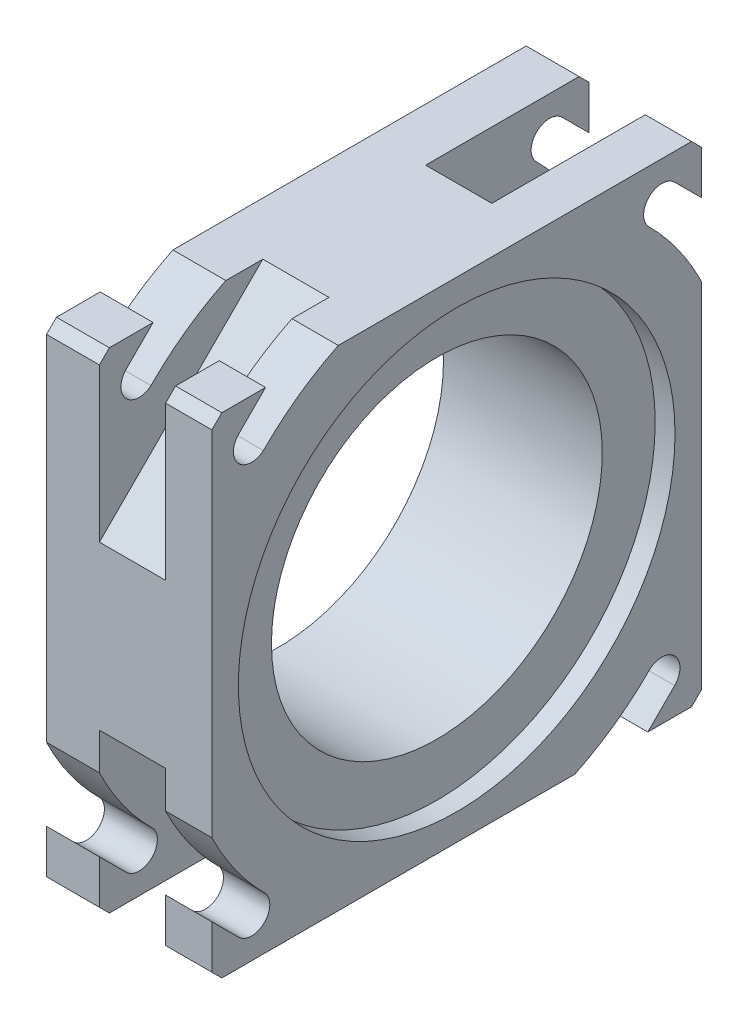
from build123d import *

# Parameters (mm, degrees)
ESBO_O1_W                                           = 74
ESBO_O1_H                                           = 74
RESSALTO_EXTRUS_O1_DEPTH                            = 25
CHANFRO1_SIZE                                       = 1.5
REBAIXO_PARA_PARAFUSO_COM_CABE_A_PANELA_D           = 50
REBAIXO_PARA_PARAFUSO_COM_CABE_A_PANELA_DEPTH       = 35
REBAIXO_PARA_PARAFUSO_COM_CABE_A_PANELA_CBORE_D     = 66
REBAIXO_PARA_PARAFUSO_COM_CABE_A_PANELA_CBORE_DEPTH = 3
REBAIXO_PARA_PARAFUSO_COM_CABE_A_PANELA_TIP         = 15.021515476
ESBO_O4_W                                           = 10
ESBO_O4_H                                           = 50
CORTE_EXTRUS_O1_DEPTH                               = 16.4
ESBO_O6_W                                           = 10
ESBO_O6_H                                           = 50
CORTE_EXTRUS_O2_DEPTH                               = 16.4
CORTE_EXTRUS_O4_REACH                               = 19.461
ESBO_O11_W                                          = 10
ESBO_O11_H                                          = 50
CORTE_EXTRUS_O3_DEPTH                               = 7
PADR_OCIRCULAR1_COUNT                               = 4
ESBO_O13_R                                          = 33
ESBO_O13_R_2                                        = 25
RESSALTO_EXTRUS_O2_DEPTH                            = 2
ESBO_O14_R                                          = 35.5
ESBO_O14_R_2                                        = 33
CORTE_EXTRUS_O5_DEPTH                               = 3.5
CORTE_EXTRUS_O10_DEPTH                              = 8
PADR_OCIRCULAR2_COUNT                               = 4
FILETE1_R                                           = 0.25
FILETE2_R                                           = 0.15


with BuildPart() as part:
    # Esboço1 → Ressalto-extrusão1 (new body)
    with BuildSketch(Plane(origin=(0, 0, 0), x_dir=(0, 0, -1), z_dir=(1, 0, 0))):
        with Locations((37, 37)):
            Rectangle(ESBO_O1_W, ESBO_O1_H)
    extrude(amount=RESSALTO_EXTRUS_O1_DEPTH)

    # Chanfro1
    chanfro1_edges = [part.edges().sort_by_distance(p)[0] for p in [
        (12.5, 74, 0),
        (12.5, 74, -74),
        (12.5, 0, -74),
        (12.5, 0, 0),
    ]]
    chamfer(chanfro1_edges, length=CHANFRO1_SIZE)

    # Rebaixo para parafuso com cabeça panela de M21
    with Locations(Plane(origin=(25, 0, 0), x_dir=(0, 0, -1), z_dir=(1, 0, 0))):
        with Locations((37, 37)):
            CounterBoreHole(REBAIXO_PARA_PARAFUSO_COM_CABE_A_PANELA_D / 2, REBAIXO_PARA_PARAFUSO_COM_CABE_A_PANELA_CBORE_D / 2, REBAIXO_PARA_PARAFUSO_COM_CABE_A_PANELA_CBORE_DEPTH, depth=REBAIXO_PARA_PARAFUSO_COM_CABE_A_PANELA_DEPTH)
            with Locations((0, 0, -(REBAIXO_PARA_PARAFUSO_COM_CABE_A_PANELA_DEPTH + REBAIXO_PARA_PARAFUSO_COM_CABE_A_PANELA_TIP / 2))):  # 118° drill point
                Cone(0, REBAIXO_PARA_PARAFUSO_COM_CABE_A_PANELA_D / 2, REBAIXO_PARA_PARAFUSO_COM_CABE_A_PANELA_TIP, mode=Mode.SUBTRACT)

    # Esboço4 → Corte-extrusão1 (cut)
    with BuildSketch(Plane(origin=(0, 12.346551211, -12.346551211), x_dir=(1, 0, 0), z_dir=(0, -0.707106781, 0.707106781))):
        with Locations((13, 0)):
            Rectangle(ESBO_O4_W, ESBO_O4_H)
    corte_extrus_o1 = extrude(amount=CORTE_EXTRUS_O1_DEPTH, mode=Mode.SUBTRACT)

    # Espelhar1: Corte-extrusão1 across plane
    add(corte_extrus_o1.mirror(Plane(origin=(0, 37, -37), x_dir=(0, 0.707106781, 0.707106781), z_dir=(0, -0.707106781, 0.707106781))), mode=Mode.SUBTRACT)

    # Esboço6 → Corte-extrusão2 (cut)
    with BuildSketch(Plane(origin=(0, -36.25, -36.25), x_dir=(1, 0, 0), z_dir=(0, -0.707106781, -0.707106781))):
        with Locations((13, -52.325901808)):
            Rectangle(ESBO_O6_W, ESBO_O6_H)
    extrude(amount=-CORTE_EXTRUS_O2_DEPTH, mode=Mode.SUBTRACT)

    # Esboço11 → Corte-extrusão4 (cut, up to next)
    with BuildSketch(Plane(origin=(0, 24.653448789, 24.653448789), x_dir=(1, 0, 0), z_dir=(0, 0.707106781, 0.707106781)), mode=Mode.PRIVATE) as corte_extrus_o4_sk1:
        with Locations((13, 52.325901808)):
            Rectangle(ESBO_O11_W, ESBO_O11_H)
    corte_extrus_o4_tool1 = extrude(corte_extrus_o4_sk1.sketch, amount=CORTE_EXTRUS_O4_REACH, mode=Mode.PRIVATE) & part.part
    add(corte_extrus_o4_tool1.solids().sort_by_distance((13, 61.653449, -12.346551))[0], mode=Mode.SUBTRACT)

    # Esboço9 → Corte-extrusão3 (cut)
    with BuildSketch(Plane(origin=(25, 0, 0), x_dir=(0, 0, -1), z_dir=(1, 0, 0))):
        with BuildLine():
            Line((8.110912703, 74), (4.055456352, 69.944543648))
            ThreePointArc((4.055456352, 69.944543648), (3.852112704, 66.282711392), (7.468916653, 65.675180896))
            ThreePointArc((7.468916653, 65.675180896), (7.630037959, 65.785169024), (7.782956276, 65.90630305))
            ThreePointArc((7.782956276, 65.90630305), (7.937911293, 66.062088707), (8.09369695, 66.217043724))
            ThreePointArc((8.09369695, 66.217043724), (13.278272682, 70.563218753), (19.105587464, 74))
            Line((19.105587464, 74), (8.110912703, 74))
        make_face()
    corte_extrus_o3 = extrude(amount=-CORTE_EXTRUS_O3_DEPTH, mode=Mode.SUBTRACT)

    # PadrãoCircular1: Corte-extrusão3 ×4 about axis
    padr_ocircular1_axis = Axis((0, 37, -37), (1, 0, 0))
    for i in range(1, PADR_OCIRCULAR1_COUNT):
        add(corte_extrus_o3.rotate(padr_ocircular1_axis, i * 360 / PADR_OCIRCULAR1_COUNT), mode=Mode.SUBTRACT)

    # Esboço13 → Ressalto-extrusão2 (add)
    with BuildSketch(Plane.ZY):
        with Locations((-37, 37)):
            Circle(ESBO_O13_R)
        with Locations((-37, 37)):
            Circle(ESBO_O13_R_2, mode=Mode.SUBTRACT)
    extrude(amount=RESSALTO_EXTRUS_O2_DEPTH)

    # Esboço14 → Corte-extrusão5 (cut)
    with BuildSketch(Plane.ZY.offset(2)):
        with Locations((-37, 37)):
            Circle(ESBO_O14_R)
        with Locations((-37, 37)):
            Circle(ESBO_O14_R_2, mode=Mode.SUBTRACT)
    extrude(amount=-CORTE_EXTRUS_O5_DEPTH, mode=Mode.SUBTRACT)

    # Esboço16 → Corte-extrusão10 (cut)
    with BuildSketch(Plane.ZY):
        with BuildLine():
            ThreePointArc((-7.782956276, 65.90630305), (-3.979263896, 66.134758569), (-4.055456352, 69.944543648))
            Line((-4.055456352, 69.944543648), (-8.110912703, 74))
            Line((-8.110912703, 74), (-19.105587464, 74))
            ThreePointArc((-19.105587464, 74), (-13.278272682, 70.563218753), (-8.09369695, 66.217043724))
            ThreePointArc((-8.09369695, 66.217043724), (-7.937911293, 66.062088707), (-7.782956276, 65.90630305))
        make_face()
    corte_extrus_o10 = extrude(amount=-CORTE_EXTRUS_O10_DEPTH, mode=Mode.SUBTRACT)

    # PadrãoCircular2: Corte-extrusão10 ×4 about axis
    padr_ocircular2_axis = Axis((0, 37, -37), (1, 0, 0))
    for i in range(1, PADR_OCIRCULAR2_COUNT):
        add(corte_extrus_o10.rotate(padr_ocircular2_axis, i * 360 / PADR_OCIRCULAR2_COUNT), mode=Mode.SUBTRACT)

    # Filete1
    filete1_edges = [part.edges().sort_by_distance(p)[0] for p in [
        (1.5, 37, -72.5),
        (1.5, 37, -70),
    ]]
    fillet(filete1_edges, radius=FILETE1_R)

    # Filete2
    filete2_edges = [part.edges().sort_by_distance(p)[0] for p in [
        (0, 37, -72.5),
    ]]
    fillet(filete2_edges, radius=FILETE2_R)


solid = part.part
